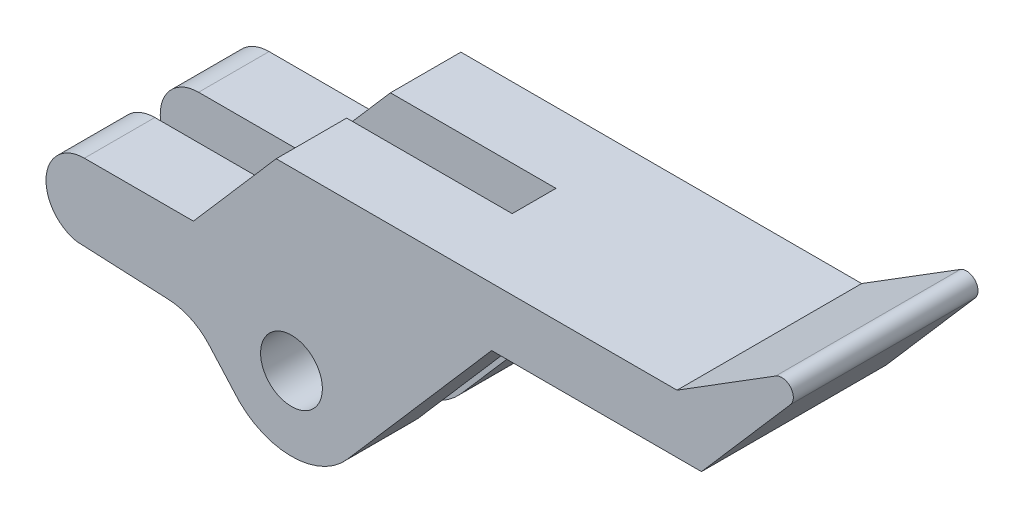
from build123d import *

# Parameters (mm, degrees)
SKETCH1_R           = 1.61
BOSS_EXTRUDE1_DEPTH = 9.62
CUT_EXTRUDE1_REACH  = 23.691
SKETCH2_W           = 2.28
SKETCH2_H           = 19.007620098
SKETCH3_W           = 11.260460121
SKETCH3_H           = 2.28
CUT_EXTRUDE2_DEPTH  = 3.04


with BuildPart() as part:
    # Sketch1 → Boss-Extrude1 (new body)
    with BuildSketch(Plane.XY):
        with BuildLine():
            Line((0, 0), (5.140631262, 3.208973392))
            ThreePointArc((5.140631262, 3.208973392), (5.914482507, 3.089800479), (5.911583106, 2.306832072))
            Line((5.911583106, 2.306832072), (1.273331069, -3.04))
            Line((1.273331069, -3.04), (-9.656668931, -3.04))
            Line((-9.656668931, -3.04), (-17.168479282, -11.699380338))
            ThreePointArc((-17.168479282, -11.699380338), (-20.147653582, -13.029479565), (-23.08154503, -11.60227095))
            Line((-23.08154503, -11.60227095), (-24.370177587, -10.154805065))
            ThreePointArc((-24.370177587, -10.154805065), (-25.319176443, -9.441943032), (-26.47036432, -9.152914355))
            Line((-26.47036432, -9.152914355), (-31.285658795, -8.927140459))
            ThreePointArc((-31.285658795, -8.927140459), (-32.860887009, -6.762353106), (-30.871741613, -4.970441053))
            Line((-30.871741613, -4.970441053), (-25.191741613, -4.970441053))
            Line((-25.191741613, -4.970441053), (-20.88, 0))
            Line((-20.88, 0), (0, 0))
        make_face()
        with Locations((-20.08426993, -9.17)):
            Circle(SKETCH1_R, mode=Mode.SUBTRACT)
    extrude(amount=BOSS_EXTRUDE1_DEPTH)

    # Cut-Extrude1: up to this face of the body (flat: up to its plane)
    cut_extrude1_end = Plane(part.part.faces().sort_by_distance((-4.191668931, -3.04, 4.81))[0])
    # Sketch2 → Cut-Extrude1 (cut, up to the picked face)
    with BuildSketch(Plane(origin=(-4.005407565, 3.474597584, 0), x_dir=(0, 0, -1), z_dir=(0.755386178, -0.65527988, 0)), mode=Mode.PRIVATE) as cut_extrude1_sk1:
        with Locations((-4.81, -18.128004893)):
            Rectangle(SKETCH2_W, SKETCH2_H)
    cut_extrude1_tool1 = split(extrude(cut_extrude1_sk1.sketch, amount=-CUT_EXTRUDE1_REACH, mode=Mode.PRIVATE), bisect_by=cut_extrude1_end, keep=Keep.BOTH, mode=Mode.PRIVATE)
    add(cut_extrude1_tool1.solids().sort_by_distance((-15.884324, -10.219047, 4.81))[0], mode=Mode.SUBTRACT)

    # Sketch3 → Cut-Extrude2 (cut)
    with BuildSketch(Plane.XZ.offset(3.04)):
        with Locations((-17.886898992, 4.81)):
            Rectangle(SKETCH3_W, SKETCH3_H)
    extrude(amount=-CUT_EXTRUDE2_DEPTH, mode=Mode.SUBTRACT)


solid = part.part
